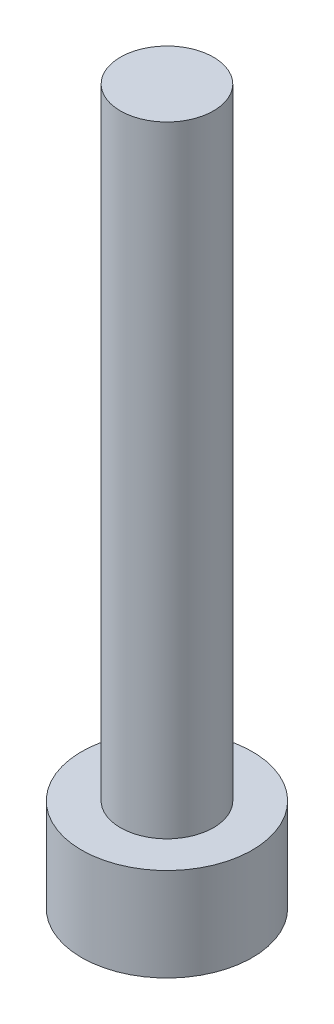
from build123d import *

# Parameters (mm, degrees)
SKETCH1_R           = 2.75
BOSS_EXTRUDE1_DEPTH = 3
SKETCH2_R           = 1.5
BOSS_EXTRUDE2_DEPTH = 20
CUT_EXTRUDE1_DEPTH  = 1.5


with BuildPart() as part:
    # Sketch1 → Boss-Extrude1 (new body)
    with BuildSketch(Plane(origin=(0, 0, 0), x_dir=(1, 0, 0), z_dir=(0, 1, 0))):
        Circle(SKETCH1_R)
    extrude(amount=BOSS_EXTRUDE1_DEPTH)

    # Sketch2 → Boss-Extrude2 (add)
    with BuildSketch(Plane(origin=(0, 3, 0), x_dir=(1, 0, 0), z_dir=(0, 1, 0))):
        Circle(SKETCH2_R)
    extrude(amount=BOSS_EXTRUDE2_DEPTH)

    # Sketch3 → Cut-Extrude1 (cut)
    with BuildSketch(Plane(origin=(0, 0, 0), x_dir=(-1, 0, 0), z_dir=(0, -1, 0))):
        Polygon((0, -1.443375673), (1.25, -0.721687836), (1.25, 0.721687836), (0, 1.443375673), (-1.25, 0.721687836), (-1.25, -0.721687836), align=None)
    extrude(amount=-CUT_EXTRUDE1_DEPTH, mode=Mode.SUBTRACT)


solid = part.part
